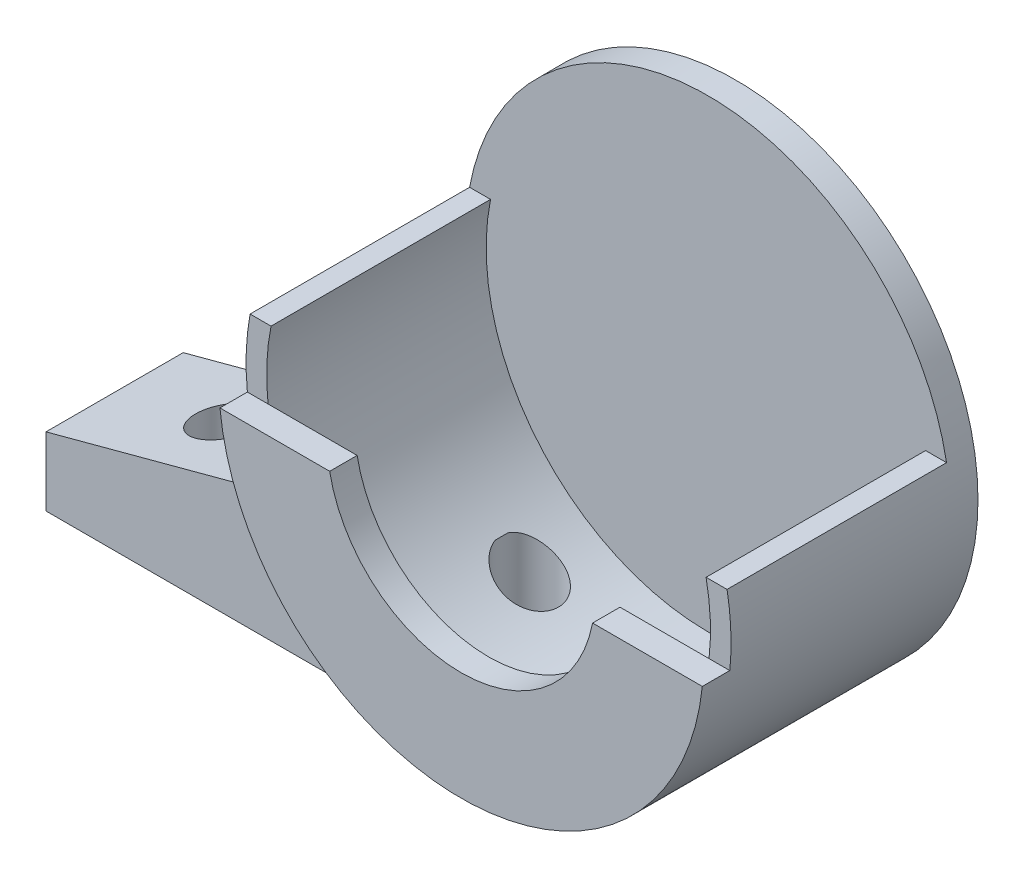
from build123d import *

# Parameters (mm, degrees)
SKETCH1_R               = 17.675
BOSS_EXTRUDE1_DEPTH     = 2
BOSS_EXTRUDE2_START     = 16
BOSS_EXTRUDE2_DEPTH     = 16
BOSS_EXTRUDE3_START     = 2
BOSS_EXTRUDE3_DEPTH     = 2
BOSS_EXTRUDE4_START     = 10
BOSS_EXTRUDE4_DEPTH     = 10
SKETCH5_R               = 2.1
CUT_EXTRUDE3_DEPTH      = 10
CUT_EXTRUDE5_DEPTH      = 47.063254879
CUT_EXTRUDE5_DEPTH_BACK = 47.063254879


with BuildPart() as part:
    # Sketch1 → Boss-Extrude1 (new body)
    with BuildSketch(Plane.XY):
        Circle(SKETCH1_R)
    extrude(amount=-BOSS_EXTRUDE1_DEPTH)

    # Sketch1_4 → Boss-Extrude2 (add)
    with BuildSketch(Plane.XY.offset(BOSS_EXTRUDE2_START)):
        with BuildLine():
            Line((-15.855302741, 3.2), (-17.382911868, 3.2))
            ThreePointArc((-17.382911868, 3.2), (-1.606651446, -17.6018265), (17.675, 0))
            ThreePointArc((17.675, 0), (17.6018265, 1.606651446), (17.382911868, 3.2))
            Line((17.382911868, 3.2), (15.855302741, 3.2))
            ThreePointArc((15.855302741, 3.2), (16.094877241, 1.607965045), (16.175, 0))
            ThreePointArc((16.175, 0), (-1.607965045, -16.094877241), (-15.855302741, 3.2))
        make_face()
    extrude(amount=-BOSS_EXTRUDE2_DEPTH)

    # Sketch2 → Boss-Extrude3 (add)
    with BuildSketch(Plane.XY.offset(16).offset(BOSS_EXTRUDE3_START)):
        with BuildLine():
            ThreePointArc((-17.580529002, -1.825), (0, -17.675), (17.580529002, -1.825))
            Line((17.580529002, -1.825), (9.580529002, -1.825))
            ThreePointArc((9.580529002, -1.825), (0, -9.752802724), (-9.580529002, -1.825))
            Line((-9.580529002, -1.825), (-17.580529002, -1.825))
        make_face()
    extrude(amount=-BOSS_EXTRUDE3_DEPTH)

    # Sketch3 → Boss-Extrude4 (add)
    with BuildSketch(Plane.XY.offset(BOSS_EXTRUDE4_START)):
        with BuildLine():
            Line((-38.257911868, -17.675), (-17.382911868, 3.2))
            ThreePointArc((-17.382911868, 3.2), (-13.582445012, -11.310296747), (0, -17.675))
            Line((0, -17.675), (0, -22.675))
            Line((0, -22.675), (-38.257911868, -22.675))
            Line((-38.257911868, -22.675), (-38.257911868, -17.675))
        make_face()
    extrude(amount=-BOSS_EXTRUDE4_DEPTH)

    # Sketch5 → Cut-Extrude3 (cut)
    with BuildSketch(Plane.XZ.offset(22.675)):
        with Locations((-30.257911868, 5)):
            Circle(SKETCH5_R)
        with Locations((-8, 5)):
            Circle(SKETCH5_R)
    extrude(amount=-CUT_EXTRUDE3_DEPTH, mode=Mode.SUBTRACT)

    # Sketch6 → Cut-Extrude5 (cut, two sides: drawn at the far end of the back side and taken through both)
    with BuildSketch(Plane.XY.offset(10).offset(-CUT_EXTRUDE5_DEPTH_BACK)):
        Polygon((-38.257911868, -17.675), (-22.582993568, -13.4749183), (-18.382911868, 2.2), align=None)
    extrude(amount=CUT_EXTRUDE5_DEPTH + CUT_EXTRUDE5_DEPTH_BACK, mode=Mode.SUBTRACT)


solid = part.part
